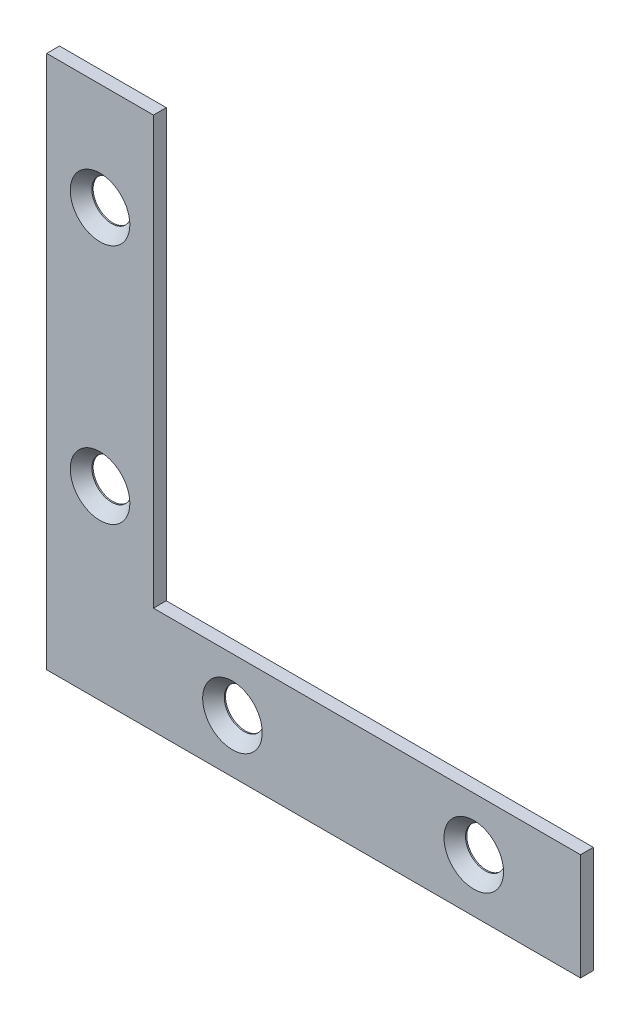
from build123d import *

# Parameters (mm, degrees)
BOSS_EXTRUDE1_DEPTH      = 0.762
BOSS_EXTRUDE1_DEPTH_BACK = 0.762
SKETCH4_R                = 2.3495
CUT_EXTRUDE1_DEPTH       = 1.762
CUT_EXTRUDE1_DEPTH_BACK  = 1.762
SKETCH5_R                = 3.5433
CUT_EXTRUDE2_DEPTH       = 2.524
CUT_EXTRUDE2_TAPER       = 41


with BuildPart() as part:
    # Sketch3 → Boss-Extrude1 (new body, two sides)
    with BuildSketch(Plane.XY) as boss_extrude1_sk:
        Polygon((-31.75, 31.75), (-19.05, 31.75), (-19.05, -19.05), (31.75, -19.05), (31.75, -31.75), (-31.75, -31.75), align=None)
    extrude(amount=BOSS_EXTRUDE1_DEPTH)
    extrude(boss_extrude1_sk.sketch, amount=-BOSS_EXTRUDE1_DEPTH_BACK)

    # Sketch4 → Cut-Extrude1 (cut, two sides)
    with BuildSketch(Plane.XY) as cut_extrude1_sk:
        with Locations((-25.4, 19.05)):
            Circle(SKETCH4_R)
        with Locations((-25.4, -9.652)):
            Circle(SKETCH4_R)
        with Locations((-9.652, -25.4)):
            Circle(SKETCH4_R)
        with Locations((19.05, -25.4)):
            Circle(SKETCH4_R)
    extrude(amount=CUT_EXTRUDE1_DEPTH, mode=Mode.SUBTRACT)
    extrude(cut_extrude1_sk.sketch, amount=-CUT_EXTRUDE1_DEPTH_BACK, mode=Mode.SUBTRACT)

    # Sketch5 → Cut-Extrude2 (cut, through all)
    with BuildSketch(Plane.XY.offset(0.762)):
        with Locations((-25.4, 19.05)):
            Circle(SKETCH5_R)
        with Locations((-25.4, -9.652)):
            Circle(SKETCH5_R)
        with Locations((-9.652, -25.4)):
            Circle(SKETCH5_R)
        with Locations((19.05, -25.4)):
            Circle(SKETCH5_R)
    extrude(amount=-CUT_EXTRUDE2_DEPTH, taper=CUT_EXTRUDE2_TAPER, mode=Mode.SUBTRACT)


solid = part.part
